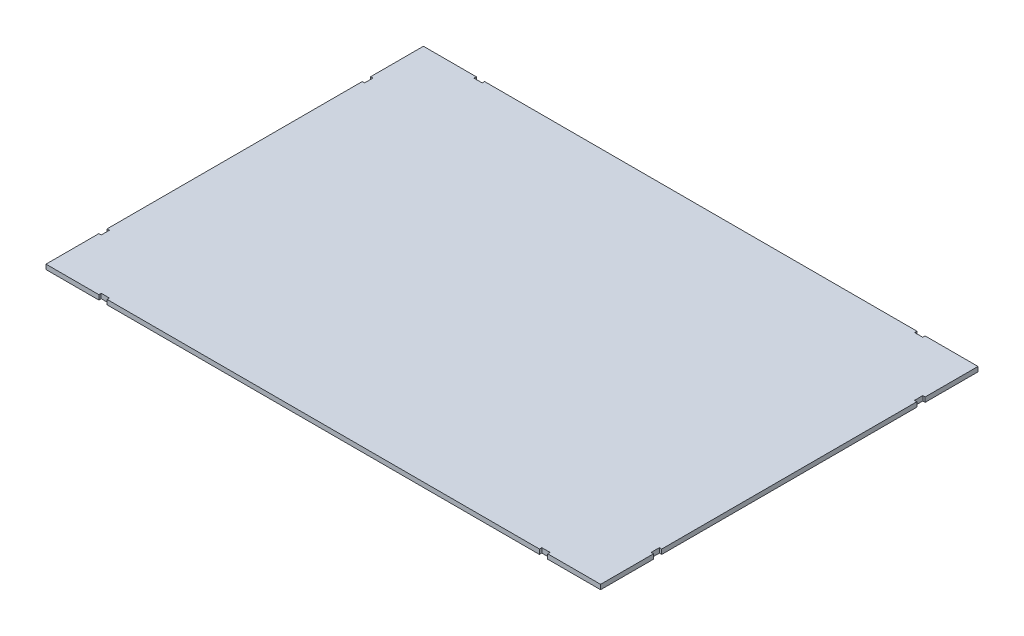
from build123d import *

# Parameters (mm, degrees)
SKETCH1_W           = 939
SKETCH1_H           = 639
BOSS_EXTRUDE1_DEPTH = 8
SKETCH2_W           = 14
SKETCH2_H           = 8
SKETCH2_W_2         = 8
SKETCH2_H_2         = 14
CUT_EXTRUDE1_DEPTH  = 9


with BuildPart() as part:
    # Sketch1 → Boss-Extrude1 (new body)
    with BuildSketch(Plane(origin=(0, 0, 0), x_dir=(1, 0, 0), z_dir=(0, 1, 0))):
        Rectangle(SKETCH1_W, SKETCH1_H)
    extrude(amount=BOSS_EXTRUDE1_DEPTH)

    # Sketch2 → Cut-Extrude1 (cut, through all)
    with BuildSketch(Plane(origin=(0, 8, 0), x_dir=(1, 0, 0), z_dir=(0, 1, 0))):
        with Locations((-373, -319.5)):
            Rectangle(SKETCH2_W, SKETCH2_H)
        with Locations((373, -319.5)):
            Rectangle(SKETCH2_W, SKETCH2_H)
        with Locations((-373, 319.5)):
            Rectangle(SKETCH2_W, SKETCH2_H)
        with Locations((-469.5, -223)):
            Rectangle(SKETCH2_W_2, SKETCH2_H_2)
        with Locations((373, 319.5)):
            Rectangle(SKETCH2_W, SKETCH2_H)
        with Locations((-469.5, 223)):
            Rectangle(SKETCH2_W_2, SKETCH2_H_2)
        with Locations((469.5, 223)):
            Rectangle(SKETCH2_W_2, SKETCH2_H_2)
        with Locations((469.5, -223)):
            Rectangle(SKETCH2_W_2, SKETCH2_H_2)
    extrude(amount=-CUT_EXTRUDE1_DEPTH, mode=Mode.SUBTRACT)


solid = part.part
